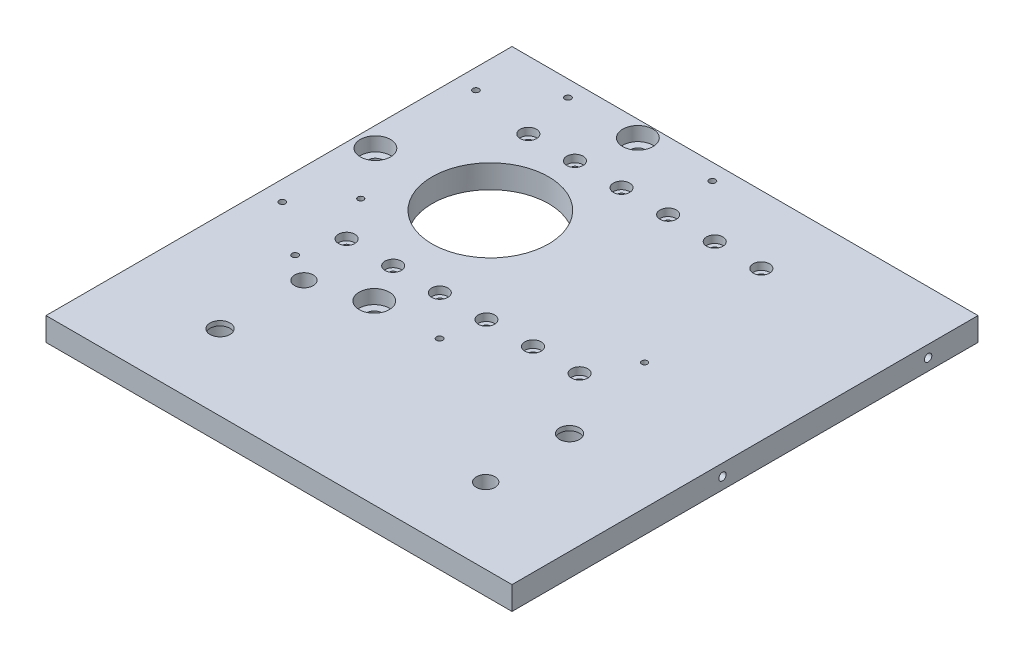
from build123d import *

# Parameters (mm, degrees)
SKETCH1_W                        = 100
SKETCH1_H                        = 100
BOSS_EXTRUDE1_DEPTH              = 5
F_25_0_25_DIAMETER_HOLE1_D       = 25
F_25_0_25_DIAMETER_HOLE1_DEPTH   = 5
CBORE_FOR_M1_6_SHCS1_D           = 1.7
CBORE_FOR_M1_6_SHCS1_DEPTH       = 5
CBORE_FOR_M1_6_SHCS1_CBORE_D     = 3.5
CBORE_FOR_M1_6_SHCS1_CBORE_DEPTH = 1.6
M1_6X0_35_TAPPED_HOLE1_D         = 1.25
M1_6X0_35_TAPPED_HOLE1_DEPTH     = 5
CBORE_FOR_M3_SHCS1_D             = 3.2
CBORE_FOR_M3_SHCS1_DEPTH         = 5
CBORE_FOR_M3_SHCS1_CBORE_D       = 6.5
CBORE_FOR_M3_SHCS1_CBORE_DEPTH   = 3
F_3_0MM_DOWEL_HOLE1_D            = 3
F_3_0MM_DOWEL_HOLE1_DEPTH        = 4.5
F_3_0MM_DOWEL_HOLE1_TIP          = 0.901290929
CBORE_FOR_M4_SHCS3_D             = 4.3
CBORE_FOR_M4_SHCS3_DEPTH         = 5
CBORE_FOR_M4_SHCS3_CBORE_D       = 8
CBORE_FOR_M4_SHCS3_CBORE_DEPTH   = 4
F_4_0MM_DOWEL_HOLE1_D            = 4
F_4_0MM_DOWEL_HOLE1_DEPTH        = 4
M2X0_4_TAPPED_HOLE1_D            = 1.6
M2X0_4_TAPPED_HOLE1_DEPTH        = 5.2
M2X0_4_TAPPED_HOLE1_TIP          = 0.480688495
M2X0_4_TAPPED_HOLE2_D            = 1.6
M2X0_4_TAPPED_HOLE2_DEPTH        = 5.2
M2X0_4_TAPPED_HOLE2_TIP          = 0.480688495


with BuildPart() as part:
    # Sketch1 → Boss-Extrude1 (new body)
    with BuildSketch(Plane(origin=(0, 0, 0), x_dir=(1, 0, 0), z_dir=(0, 1, 0))):
        Rectangle(SKETCH1_W, SKETCH1_H)
    extrude(amount=BOSS_EXTRUDE1_DEPTH)

    # Ø25.0 (25) Diameter Hole1
    with Locations(Plane(origin=(0, 5, 0), x_dir=(1, 0, 0), z_dir=(0, 1, 0))):
        with Locations((-21.874935549, 17.227744249)):
            Hole(F_25_0_25_DIAMETER_HOLE1_D / 2, depth=F_25_0_25_DIAMETER_HOLE1_DEPTH)

    # CBORE for M1.6 SHCS1
    with Locations(Plane(origin=(0, 5, 0), x_dir=(1, 0, 0), z_dir=(0, 1, 0))):
        with Locations((-32, 35.504948403), (-22, 35.504948403), (-12, 35.504948403), (-2, 35.504948403), (8, 35.504948403), (18, 35.504948403), (18, -3.495051597), (8, -3.495051597), (-2, -3.495051597), (-12, -3.495051597), (-22, -3.495051597), (-32, -3.495051597)):
            CounterBoreHole(CBORE_FOR_M1_6_SHCS1_D / 2, CBORE_FOR_M1_6_SHCS1_CBORE_D / 2, CBORE_FOR_M1_6_SHCS1_CBORE_DEPTH, depth=CBORE_FOR_M1_6_SHCS1_DEPTH)

    # M1.6x0.35 Tapped Hole1
    with Locations(Plane(origin=(0, 0, 0), x_dir=(-1, 0, 0), z_dir=(0, -1, 0))):
        with Locations((37.961945314, 5.5), (-22.961945314, 5.5)):
            Hole(M1_6X0_35_TAPPED_HOLE1_D / 2, depth=M1_6X0_35_TAPPED_HOLE1_DEPTH)

    # CBORE for M3 SHCS1
    with Locations(Plane(origin=(0, 5, 0), x_dir=(1, 0, 0), z_dir=(0, 1, 0))):
        with Locations((-19.518211542, 46.528144303), (-45.766139787, 16.455389216), (-17.50826472, -12.046305538)):
            CounterBoreHole(CBORE_FOR_M3_SHCS1_D / 2, CBORE_FOR_M3_SHCS1_CBORE_D / 2, CBORE_FOR_M3_SHCS1_CBORE_DEPTH, depth=CBORE_FOR_M3_SHCS1_DEPTH)

    # Ø3.0mm Dowel Hole1
    with Locations(Plane(origin=(0, 0, 0), x_dir=(-1, 0, 0), z_dir=(0, -1, 0))):
        with Locations((3.5, -12.04), (34.5, -12.04), (45.75, -3.54), (45.75, 38), (34.5, 46.5), (3.5, 46.5)):
            Hole(F_3_0MM_DOWEL_HOLE1_D / 2, depth=F_3_0MM_DOWEL_HOLE1_DEPTH)
            with Locations((0, 0, -(F_3_0MM_DOWEL_HOLE1_DEPTH + F_3_0MM_DOWEL_HOLE1_TIP / 2))):  # 118° drill point
                Cone(0, F_3_0MM_DOWEL_HOLE1_D / 2, F_3_0MM_DOWEL_HOLE1_TIP, mode=Mode.SUBTRACT)

    # CBORE for M4 SHCS3
    with Locations(Plane(origin=(0, 0, 0), x_dir=(-1, 0, 0), z_dir=(0, -1, 0))):
        with Locations((28.876959135, -33.77675291), (-28.120192829, -15.777088357)):
            CounterBoreHole(CBORE_FOR_M4_SHCS3_D / 2, CBORE_FOR_M4_SHCS3_CBORE_D / 2, CBORE_FOR_M4_SHCS3_CBORE_DEPTH, depth=CBORE_FOR_M4_SHCS3_DEPTH)

    # Ø4.0mm Dowel Hole1
    with Locations(Plane(origin=(0, 5, 0), x_dir=(1, 0, 0), z_dir=(0, 1, 0))):
        with Locations((-28.874935549, -15.772255751), (28.125064451, -33.772255751)):
            Hole(F_4_0MM_DOWEL_HOLE1_D / 2, depth=F_4_0MM_DOWEL_HOLE1_DEPTH)

    # M2x0.4 Tapped Hole1
    with Locations(Plane(origin=(0, 0, -50), x_dir=(-1, 0, 0), z_dir=(0, 0, -1))):
        with Locations((-27.556293219, 2.5)):
            Hole(M2X0_4_TAPPED_HOLE1_D / 2, depth=M2X0_4_TAPPED_HOLE1_DEPTH)
            with Locations((0, 0, -(M2X0_4_TAPPED_HOLE1_DEPTH + M2X0_4_TAPPED_HOLE1_TIP / 2))):  # 118° drill point
                Cone(0, M2X0_4_TAPPED_HOLE1_D / 2, M2X0_4_TAPPED_HOLE1_TIP, mode=Mode.SUBTRACT)

    # M2x0.4 Tapped Hole2
    with Locations(Plane(origin=(50, 0, 0), x_dir=(0, 0, -1), z_dir=(1, 0, 0))):
        with Locations((-4.832893219, 2.5), (39.292893219, 2.5)):
            Hole(M2X0_4_TAPPED_HOLE2_D / 2, depth=M2X0_4_TAPPED_HOLE2_DEPTH)
            with Locations((0, 0, -(M2X0_4_TAPPED_HOLE2_DEPTH + M2X0_4_TAPPED_HOLE2_TIP / 2))):  # 118° drill point
                Cone(0, M2X0_4_TAPPED_HOLE2_D / 2, M2X0_4_TAPPED_HOLE2_TIP, mode=Mode.SUBTRACT)


solid = part.part
